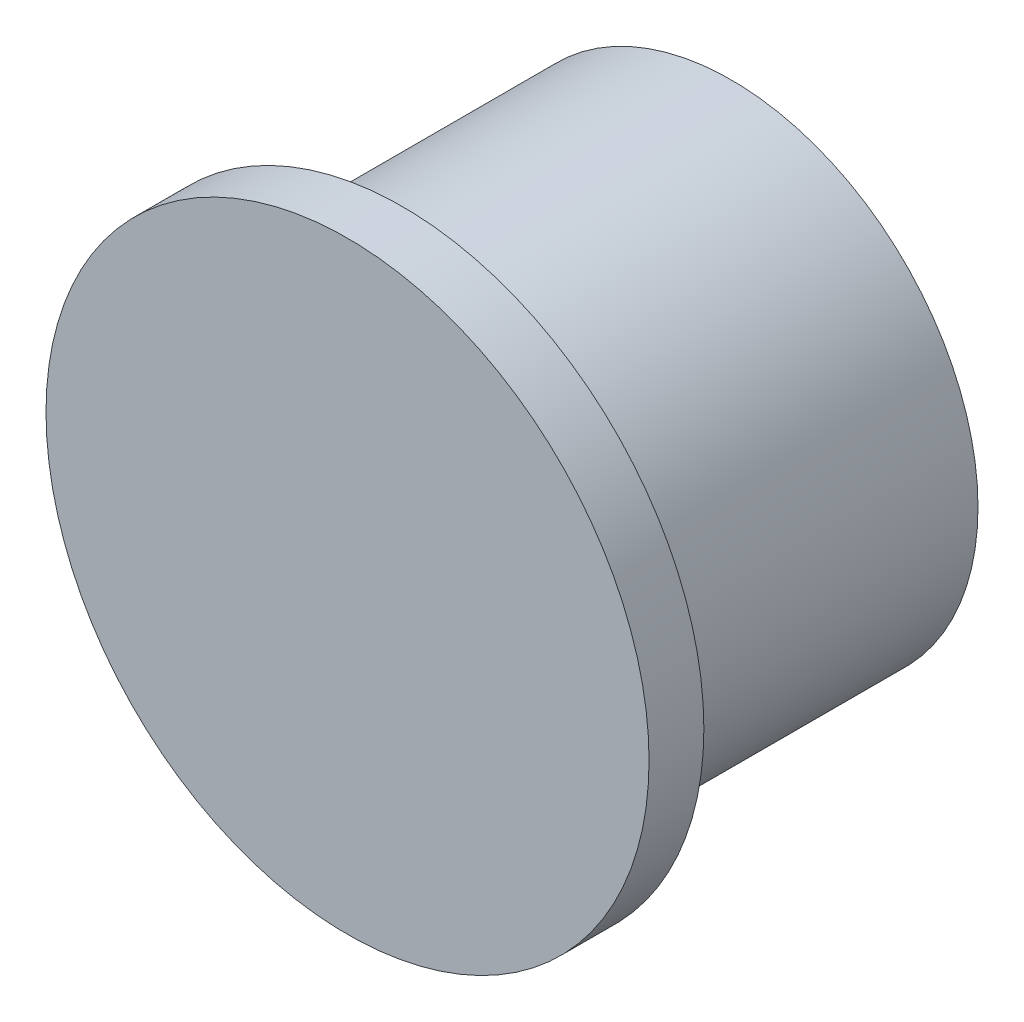
from build123d import *

# Parameters (mm, degrees)
SKETCH1_R           = 11
BOSS_EXTRUDE1_DEPTH = 2
SKETCH2_R           = 9
BOSS_EXTRUDE2_DEPTH = 12


with BuildPart() as part:
    # Sketch1 → Boss-Extrude1 (new body)
    with BuildSketch(Plane.XY):
        Circle(SKETCH1_R)
    extrude(amount=BOSS_EXTRUDE1_DEPTH)

    # Sketch2 → Boss-Extrude2 (add)
    with BuildSketch(Plane(origin=(0, 0, 0), x_dir=(-1, 0, 0), z_dir=(0, 0, -1))):
        Circle(SKETCH2_R)
    extrude(amount=BOSS_EXTRUDE2_DEPTH)


solid = part.part
